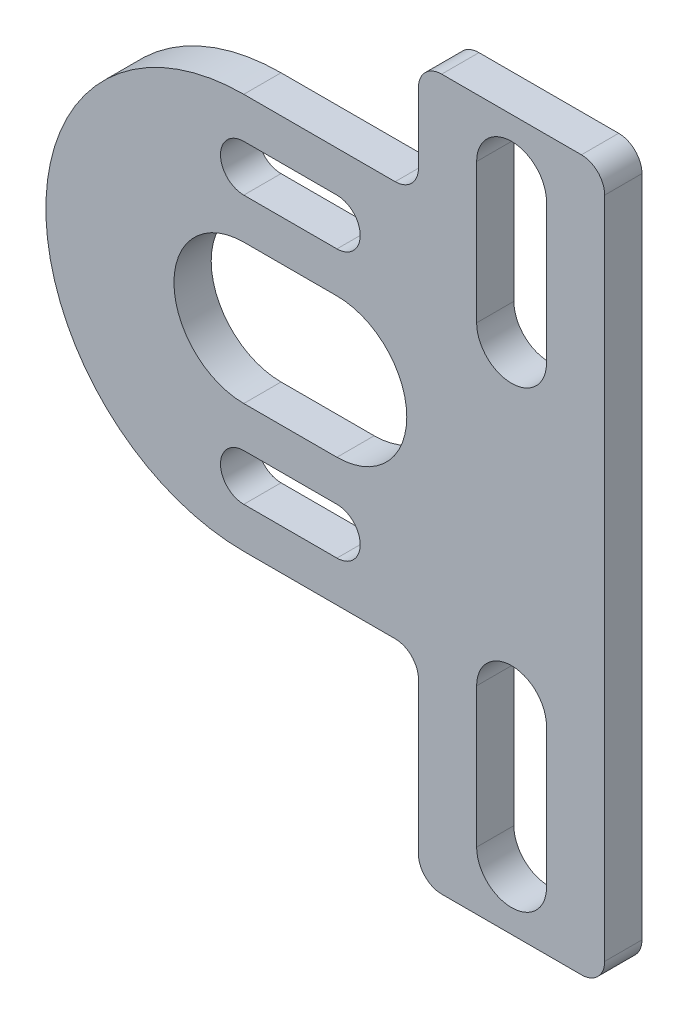
from build123d import *

# Parameters (mm, degrees)
EXTRUDE_1_DEPTH = 1.6
FILLET_1_R      = 1


with BuildPart() as part:
    # 草图1 → 凸台-拉伸1 (new body)
    with BuildSketch(Plane.XY):
        with BuildLine():
            Line((-0.5, 8.5), (7, 8.5))
            Line((7, 8.5), (7, 13.5))
            Line((7, 13.5), (15, 13.5))
            Line((15, 13.5), (15, -17))
            Line((15, -17), (7, -17))
            Line((7, -17), (7, -8.5))
            Line((7, -8.5), (-0.5, -8.5))
            ThreePointArc((-0.5, -8.5), (-9, 0), (-0.5, 8.5))
        make_face()
        with BuildLine():
            Line((-0.5, 3), (3.5, 3))
            ThreePointArc((3.5, 3), (6.5, 0), (3.5, -3))
            Line((3.5, -3), (-0.5, -3))
            ThreePointArc((-0.5, -3), (-3.5, 0), (-0.5, 3))
        make_face(mode=Mode.SUBTRACT)
        with BuildLine():
            Line((-0.5, 6.75), (3.5, 6.75))
            ThreePointArc((3.5, 6.75), (4.5, 5.75), (3.5, 4.75))
            Line((3.5, 4.75), (-0.5, 4.75))
            ThreePointArc((-0.5, 4.75), (-1.5, 5.75), (-0.5, 6.75))
        make_face(mode=Mode.SUBTRACT)
        with BuildLine():
            Line((-0.5, -6.75), (3.5, -6.75))
            ThreePointArc((3.5, -6.75), (4.5, -5.75), (3.5, -4.75))
            Line((3.5, -4.75), (-0.5, -4.75))
            ThreePointArc((-0.5, -4.75), (-1.5, -5.75), (-0.5, -6.75))
        make_face(mode=Mode.SUBTRACT)
        with BuildLine():
            Line((12.5, -8.5), (12.5, -14.5))
            ThreePointArc((12.5, -14.5), (11, -16), (9.5, -14.5))
            Line((9.5, -14.5), (9.5, -8.5))
            ThreePointArc((9.5, -8.5), (11, -7), (12.5, -8.5))
        make_face(mode=Mode.SUBTRACT)
        with BuildLine():
            Line((12.5, 5), (12.5, 11))
            ThreePointArc((12.5, 11), (11, 12.5), (9.5, 11))
            Line((9.5, 11), (9.5, 5))
            ThreePointArc((9.5, 5), (11, 3.5), (12.5, 5))
        make_face(mode=Mode.SUBTRACT)
    extrude(amount=EXTRUDE_1_DEPTH)

    # 圆角1
    fillet_1_edges = [part.edges().sort_by_distance(p)[0] for p in [
        (7, 8.5, 0.8),
        (7, 13.5, 0.8),
        (15, 13.5, 0.8),
        (15, -17, 0.8),
        (7, -17, 0.8),
        (7, -8.5, 0.8),
    ]]
    fillet(fillet_1_edges, radius=FILLET_1_R)


solid = part.part
